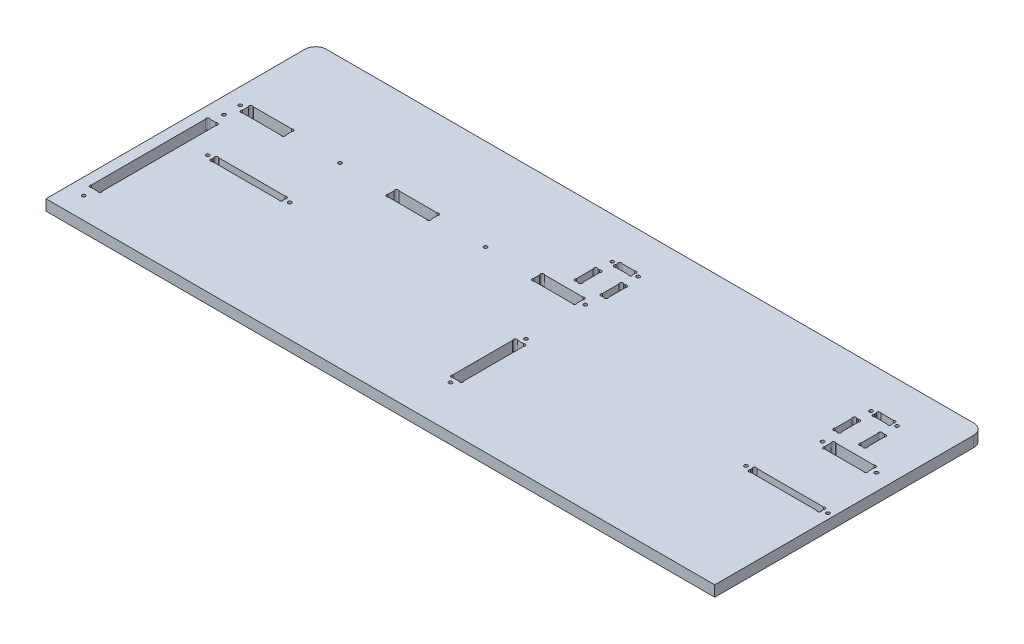
from build123d import *

# Parameters (mm, degrees)
ESQUISSE1_R      = 1.6
EXTRUSION1_DEPTH = 10


with BuildPart() as part:
    # Esquisse1 → Extrusion1 (new body)
    with BuildSketch(Plane(origin=(0, 0, 0), x_dir=(1, 0, 0), z_dir=(0, 1, 0))):
        with BuildLine():
            Line((10, 250), (610, 250))
            ThreePointArc((610, 250), (617.071067812, 247.071067812), (620, 240))
            Line((620, 240), (620, 0))
            Line((620, 0), (0, 0))
            Line((0, 0), (0, 240))
            ThreePointArc((0, 240), (2.928932188, 247.071067812), (10, 250))
        make_face()
        with Locations(Location((313, 212, 0), (0, 0, 270))):  # turned: the seam where the file's is
            Circle(ESQUISSE1_R, mode=Mode.SUBTRACT)
        with Locations(Location((337, 212, 0), (0, 0, 90))):  # turned: the seam where the file's is
            Circle(ESQUISSE1_R, mode=Mode.SUBTRACT)
        with Locations(Location((553, 212, 0), (0, 0, 270))):  # turned: the seam where the file's is
            Circle(ESQUISSE1_R, mode=Mode.SUBTRACT)
        with Locations(Location((577, 212, 0), (0, 0, 90))):  # turned: the seam where the file's is
            Circle(ESQUISSE1_R, mode=Mode.SUBTRACT)
        with Locations(Location((555, 165, 0), (0, 0, 270))):  # turned: the seam where the file's is
            Circle(ESQUISSE1_R, mode=Mode.SUBTRACT)
        with Locations(Location((605, 165, 0), (0, 0, 90))):  # turned: the seam where the file's is
            Circle(ESQUISSE1_R, mode=Mode.SUBTRACT)
        with Locations(Location((335, 165, 0), (0, 0, 90))):  # turned: the seam where the file's is
            Circle(ESQUISSE1_R, mode=Mode.SUBTRACT)
        with Locations(Location((15, 165, 0), (0, 0, 270))):  # turned: the seam where the file's is
            Circle(ESQUISSE1_R, mode=Mode.SUBTRACT)
        with Locations(Location((242.5, 165, 0), (0, 0, 270))):  # turned: the seam where the file's is
            Circle(ESQUISSE1_R, mode=Mode.SUBTRACT)
        with Locations(Location((107.5, 165, 0), (0, 0, 90))):  # turned: the seam where the file's is
            Circle(ESQUISSE1_R, mode=Mode.SUBTRACT)
        with Locations(Location((15, 20, 0), (0, 0, 270))):  # turned: the seam where the file's is
            Circle(ESQUISSE1_R, mode=Mode.SUBTRACT)
        with Locations(Location((15, 150, 0), (0, 0, 90))):  # turned: the seam where the file's is
            Circle(ESQUISSE1_R, mode=Mode.SUBTRACT)
        with Locations(Location((335, 40, 0), (0, 0, 270))):  # turned: the seam where the file's is
            Circle(ESQUISSE1_R, mode=Mode.SUBTRACT)
        with Locations(Location((335, 110, 0), (0, 0, 90))):  # turned: the seam where the file's is
            Circle(ESQUISSE1_R, mode=Mode.SUBTRACT)
        with Locations(Location((615, 110, 0), (0, 0, 270))):  # turned: the seam where the file's is
            Circle(ESQUISSE1_R, mode=Mode.SUBTRACT)
        with Locations(Location((539, 110, 0), (0, 0, 90))):  # turned: the seam where the file's is
            Circle(ESQUISSE1_R, mode=Mode.SUBTRACT)
        with Locations(Location((116, 110, 0), (0, 0, 270))):  # turned: the seam where the file's is
            Circle(ESQUISSE1_R, mode=Mode.SUBTRACT)
        with Locations(Location((40, 110, 0), (0, 0, 90))):  # turned: the seam where the file's is
            Circle(ESQUISSE1_R, mode=Mode.SUBTRACT)
        with BuildLine():
            Line((317, 211.2627417), (317, 212.7372583))
            ThreePointArc((317, 212.7372583), (317, 215), (319.2627417, 215))
            Line((319.2627417, 215), (330.7372583, 215))
            ThreePointArc((330.7372583, 215), (333, 215), (333, 212.7372583))
            Line((333, 212.7372583), (333, 211.2627417))
            ThreePointArc((333, 211.2627417), (333, 209), (330.737258301, 209))
            Line((330.737258301, 209), (319.262741699, 209))
            ThreePointArc((319.262741699, 209), (316.999999999, 209.000000001), (317, 211.2627417))
        make_face(mode=Mode.SUBTRACT)
        with BuildLine():
            Line((312.262741699, 179.5), (313.737258301, 179.5))
            ThreePointArc((313.737258301, 179.5), (316.000000001, 179.500000001), (316, 181.762741701))
            Line((316, 181.762741701), (316, 197.237258299))
            ThreePointArc((316, 197.237258299), (316.000000001, 199.499999999), (313.737258301, 199.5))
            Line((313.737258301, 199.5), (312.262741699, 199.5))
            ThreePointArc((312.262741699, 199.5), (309.999999999, 199.499999999), (310, 197.237258299))
            Line((310, 197.237258299), (310, 181.762741701))
            ThreePointArc((310, 181.762741701), (309.999999999, 179.500000001), (312.262741699, 179.5))
        make_face(mode=Mode.SUBTRACT)
        with BuildLine():
            Line((334, 181.762741701), (334, 197.2372583))
            ThreePointArc((334, 197.2372583), (334, 199.5), (336.2627417, 199.5))
            Line((336.2627417, 199.5), (337.7372583, 199.5))
            ThreePointArc((337.7372583, 199.5), (340, 199.5), (340, 197.2372583))
            Line((340, 197.2372583), (340, 181.762741701))
            ThreePointArc((340, 181.762741701), (340.000000001, 179.500000001), (337.737258301, 179.5))
            Line((337.737258301, 179.5), (336.262741699, 179.5))
            ThreePointArc((336.262741699, 179.5), (333.999999999, 179.500000001), (334, 181.762741701))
        make_face(mode=Mode.SUBTRACT)
        with BuildLine():
            Line((552.2627417, 179.5), (553.7372583, 179.5))
            ThreePointArc((553.7372583, 179.5), (556, 179.5), (556, 181.7627417))
            Line((556, 181.7627417), (556, 197.2372583))
            ThreePointArc((556, 197.2372583), (556, 199.5), (553.7372583, 199.5))
            Line((553.7372583, 199.5), (552.2627417, 199.5))
            ThreePointArc((552.2627417, 199.5), (550, 199.5), (550, 197.2372583))
            Line((550, 197.2372583), (550, 181.7627417))
            ThreePointArc((550, 181.7627417), (550, 179.5), (552.2627417, 179.5))
        make_face(mode=Mode.SUBTRACT)
        with BuildLine():
            Line((574, 181.7627417), (574, 197.2372583))
            ThreePointArc((574, 197.2372583), (574, 199.5), (576.2627417, 199.5))
            Line((576.2627417, 199.5), (577.7372583, 199.5))
            ThreePointArc((577.7372583, 199.5), (580, 199.5), (580, 197.2372583))
            Line((580, 197.2372583), (580, 181.7627417))
            ThreePointArc((580, 181.7627417), (580, 179.5), (577.7372583, 179.5))
            Line((577.7372583, 179.5), (576.2627417, 179.5))
            ThreePointArc((576.2627417, 179.5), (574, 179.5), (574, 181.7627417))
        make_face(mode=Mode.SUBTRACT)
        with BuildLine():
            Line((559.2627417, 209), (570.7372583, 209))
            ThreePointArc((570.7372583, 209), (573, 209), (573, 211.2627417))
            Line((573, 211.2627417), (573, 212.7372583))
            ThreePointArc((573, 212.7372583), (573, 215), (570.7372583, 215))
            Line((570.7372583, 215), (559.2627417, 215))
            ThreePointArc((559.2627417, 215), (557, 215), (557, 212.7372583))
            Line((557, 212.7372583), (557, 211.2627417))
            ThreePointArc((557, 211.2627417), (557, 209), (559.2627417, 209))
        make_face(mode=Mode.SUBTRACT)
        with BuildLine():
            Line((560, 167.7372583), (560, 162.2627417))
            ThreePointArc((560, 162.2627417), (560, 160), (562.2627417, 160))
            Line((562.2627417, 160), (597.7372583, 160))
            ThreePointArc((597.7372583, 160), (600, 160), (600, 162.2627417))
            Line((600, 162.2627417), (600, 167.7372583))
            ThreePointArc((600, 167.7372583), (600, 170), (597.7372583, 170))
            Line((597.7372583, 170), (562.2627417, 170))
            ThreePointArc((562.2627417, 170), (560, 170), (560, 167.7372583))
        make_face(mode=Mode.SUBTRACT)
        with BuildLine():
            Line((292.2627417, 160), (327.7372583, 160))
            ThreePointArc((327.7372583, 160), (330, 160), (330, 162.2627417))
            Line((330, 162.2627417), (330, 167.7372583))
            ThreePointArc((330, 167.7372583), (330, 170), (327.7372583, 170))
            Line((327.7372583, 170), (292.2627417, 170))
            ThreePointArc((292.2627417, 170), (290, 170), (290, 167.7372583))
            Line((290, 167.7372583), (290, 162.2627417))
            ThreePointArc((290, 162.2627417), (290, 160), (292.2627417, 160))
        make_face(mode=Mode.SUBTRACT)
        with BuildLine():
            Line((20, 167.7372583), (20, 162.2627417))
            ThreePointArc((20, 162.2627417), (20, 160), (22.2627417, 160))
            Line((22.2627417, 160), (57.7372583, 160))
            ThreePointArc((57.7372583, 160), (60, 160), (60, 162.2627417))
            Line((60, 162.2627417), (60, 167.7372583))
            ThreePointArc((60, 167.7372583), (60, 170), (57.7372583, 170))
            Line((57.7372583, 170), (22.2627417, 170))
            ThreePointArc((22.2627417, 170), (20, 170), (20, 167.7372583))
        make_face(mode=Mode.SUBTRACT)
        with BuildLine():
            Line((155, 167.7372583), (155, 162.2627417))
            ThreePointArc((155, 162.2627417), (155, 160), (157.2627417, 160))
            Line((157.2627417, 160), (192.7372583, 160))
            ThreePointArc((192.7372583, 160), (195, 160), (195, 162.2627417))
            Line((195, 162.2627417), (195, 167.7372583))
            ThreePointArc((195, 167.7372583), (195, 170), (192.7372583, 170))
            Line((192.7372583, 170), (157.2627417, 170))
            ThreePointArc((157.2627417, 170), (155, 170), (155, 167.7372583))
        make_face(mode=Mode.SUBTRACT)
        with BuildLine():
            Line((12.2627417, 30), (17.7372583, 30))
            ThreePointArc((17.7372583, 30), (20, 30), (20, 32.2627417))
            Line((20, 32.2627417), (20, 137.7372583))
            ThreePointArc((20, 137.7372583), (20, 140), (17.7372583, 140))
            Line((17.7372583, 140), (12.2627417, 140))
            ThreePointArc((12.2627417, 140), (10, 140), (10, 137.7372583))
            Line((10, 137.7372583), (10, 32.2627417))
            ThreePointArc((10, 32.2627417), (10, 30), (12.2627417, 30))
        make_face(mode=Mode.SUBTRACT)
        with BuildLine():
            Line((337.7372583, 45), (332.2627417, 45))
            ThreePointArc((332.2627417, 45), (330, 45), (330, 47.2627417))
            Line((330, 47.2627417), (330, 102.7372583))
            ThreePointArc((330, 102.7372583), (330, 105), (332.2627417, 105))
            Line((332.2627417, 105), (337.7372583, 105))
            ThreePointArc((337.7372583, 105), (340, 105), (340, 102.7372583))
            Line((340, 102.7372583), (340, 47.2627417))
            ThreePointArc((340, 47.2627417), (340, 45), (337.7372583, 45))
        make_face(mode=Mode.SUBTRACT)
        with BuildLine():
            Line((610, 109.2627417), (610, 110.7372583))
            ThreePointArc((610, 110.7372583), (610, 113), (607.7372583, 113))
            Line((607.7372583, 113), (546.2627417, 113))
            ThreePointArc((546.2627417, 113), (544, 113), (544, 110.7372583))
            Line((544, 110.7372583), (544, 109.2627417))
            ThreePointArc((544, 109.2627417), (544, 107), (546.2627417, 107))
            Line((546.2627417, 107), (607.7372583, 107))
            ThreePointArc((607.7372583, 107), (610, 107), (610, 109.2627417))
        make_face(mode=Mode.SUBTRACT)
        with BuildLine():
            Line((108.7372583, 113), (47.2627417, 113))
            ThreePointArc((47.2627417, 113), (45, 113), (45, 110.7372583))
            Line((45, 110.7372583), (45, 109.2627417))
            ThreePointArc((45, 109.2627417), (45, 107), (47.2627417, 107))
            Line((47.2627417, 107), (108.7372583, 107))
            ThreePointArc((108.7372583, 107), (111, 107), (111, 109.2627417))
            Line((111, 109.2627417), (111, 110.7372583))
            ThreePointArc((111, 110.7372583), (111, 113), (108.7372583, 113))
        make_face(mode=Mode.SUBTRACT)
    extrude(amount=EXTRUSION1_DEPTH)


solid = part.part
